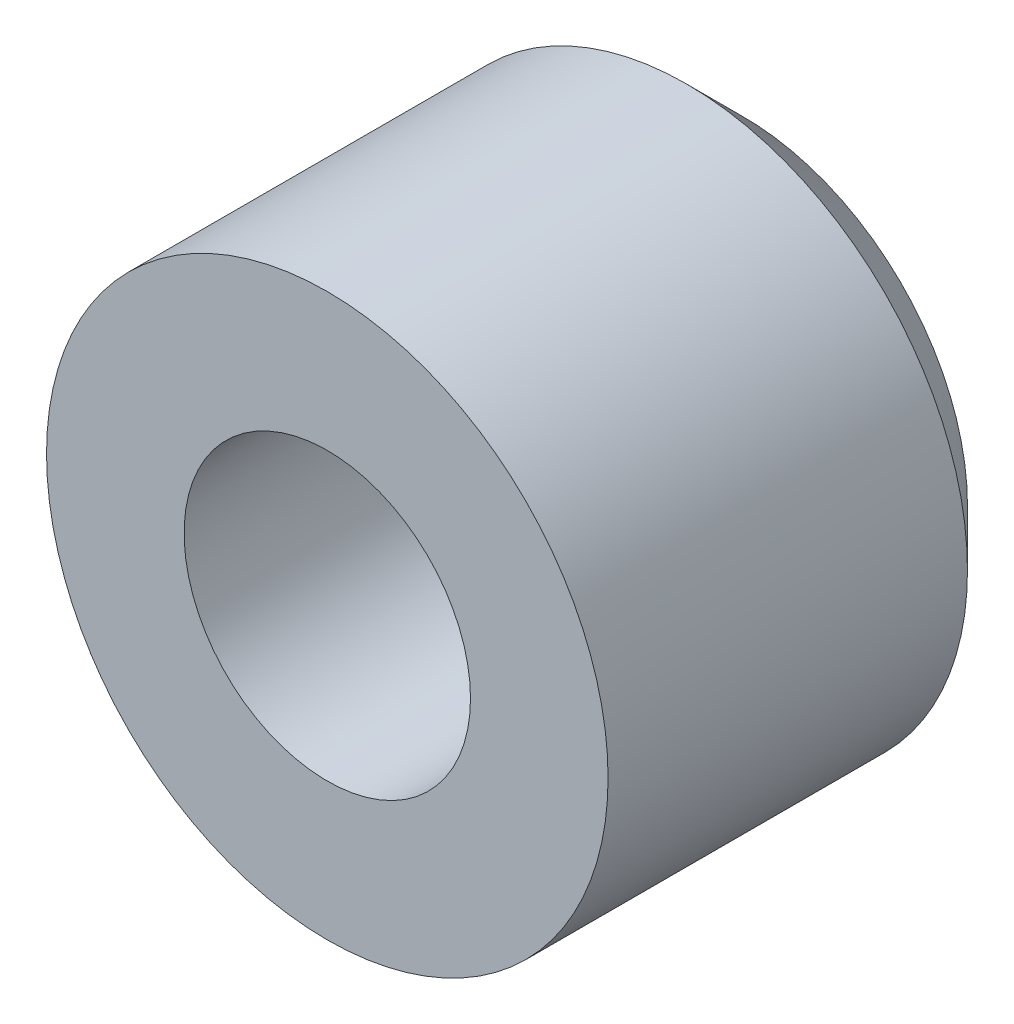
from build123d import *

# Parameters (mm, degrees)
SKETCH_1_R    = 5
SKETCH_1_R_2  = 2.55
BODY_DEPTH    = 7.4
CHAMFER1_SIZE = 1


with BuildPart() as part:
    # Эскиз1 → Body (new body)
    with BuildSketch(Plane.XY):
        Circle(SKETCH_1_R)
        Circle(SKETCH_1_R_2, mode=Mode.SUBTRACT)
    extrude(amount=BODY_DEPTH)

    # Chamfer1
    chamfer1_edges = [part.edges().sort_by_distance(p)[0] for p in [
        (-5, 0, 0),
    ]]
    chamfer(chamfer1_edges, length=CHAMFER1_SIZE)


solid = part.part
